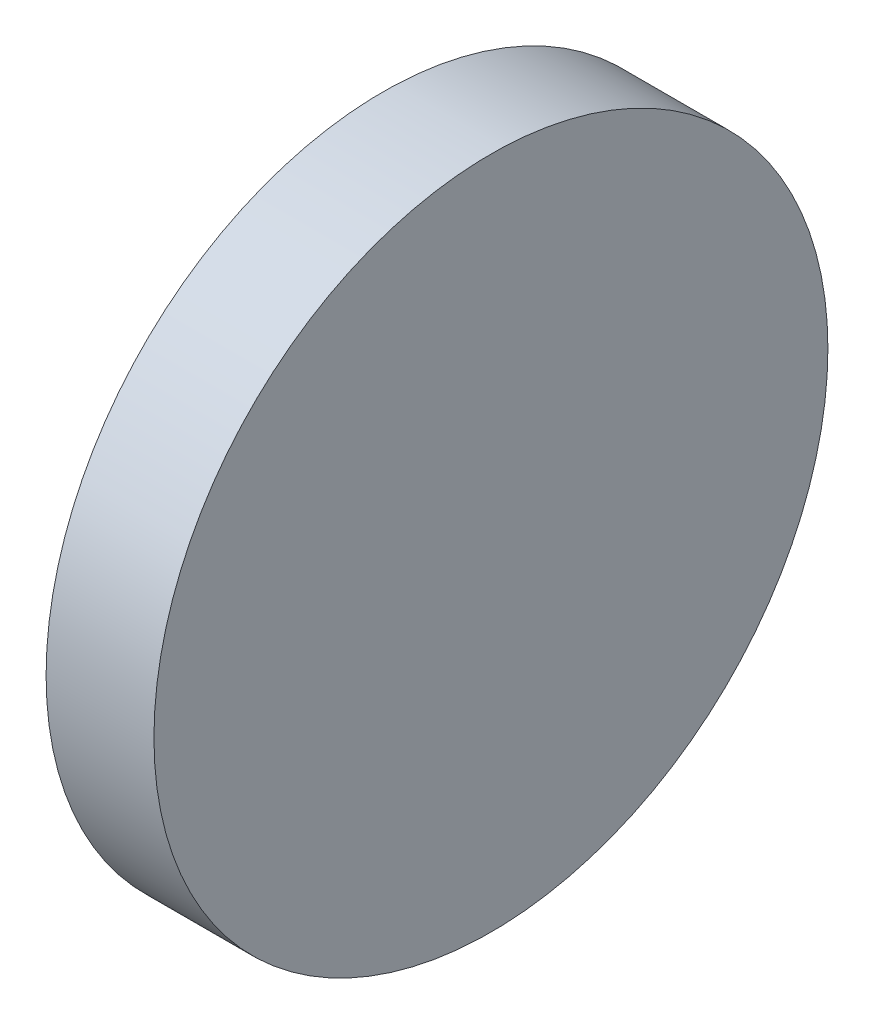
from build123d import *

# Parameters (mm, degrees)
SKETCH_1_W = 2
SKETCH_1_H = 6.25


with BuildPart() as part:
    # 草图1 → 旋转1 (revolve)
    with BuildSketch(Plane.XY, mode=Mode.PRIVATE) as revolve_1_sk:
        with Locations((131.078570246, 41.771589675)):
            Rectangle(SKETCH_1_W, SKETCH_1_H)
    revolve(revolve_1_sk.sketch.rotate(Axis((127.000400996, 38.646589675, 0), (1, 0, 0)), 90), axis=Axis((127.000400996, 38.646589675, 0), (1, 0, 0)))  # turned: the seam where the file's is


solid = part.part
